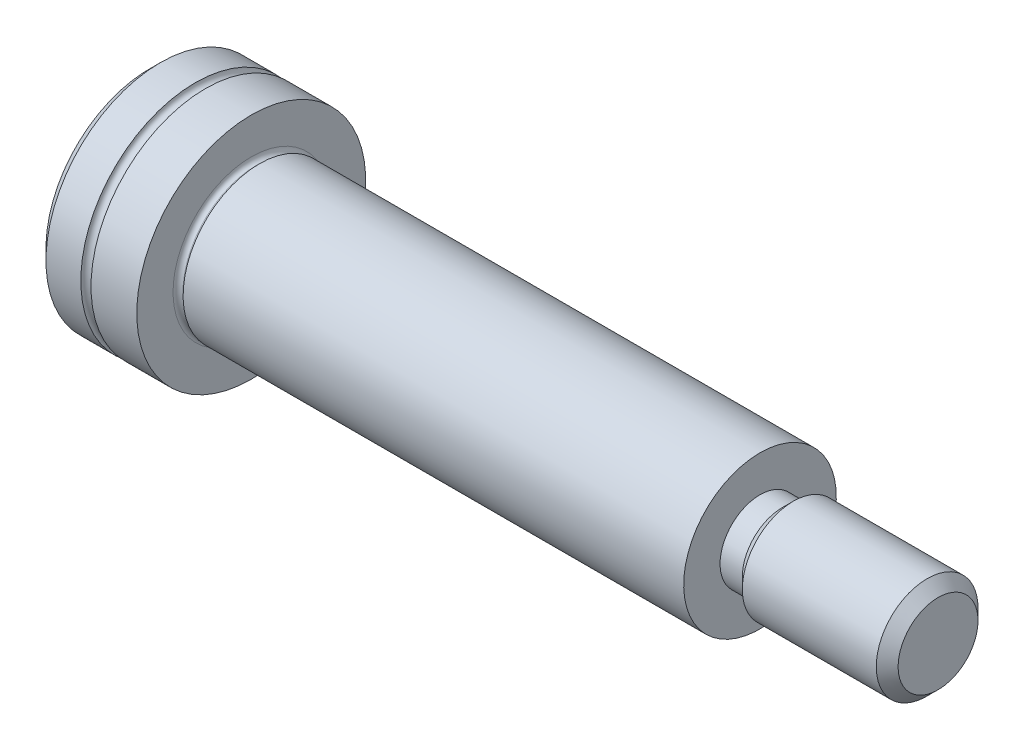
from build123d import *

# Parameters (mm, degrees)
SKETCH2_R           = 2.88
BOSS_EXTRUDE1_DEPTH = 0.250717968
SKETCH3_R           = 2.88
BOSS_EXTRUDE2_DEPTH = 0.069282032
BOSS_EXTRUDE2_TAPER = -60.000000004
SKETCH4_R           = 3
BOSS_EXTRUDE3_DEPTH = 19.68
SKETCH5_R           = 1.5705
BOSS_EXTRUDE4_DEPTH = 0.875
SKETCH6_R           = 1.5705
BOSS_EXTRUDE5_DEPTH = 0.4295
BOSS_EXTRUDE5_TAPER = -45
SKETCH7_R           = 2
BOSS_EXTRUDE6_DEPTH = 5.6955
CUT_EXTRUDE1_DEPTH  = 2
CHAMFER1_SIZE       = 0.4295
FILLET1_R           = 0.195


with BuildPart() as part:
    # Sketch1 → Revolve1 (revolve)
    with BuildSketch(Plane(origin=(0, 0, 0), x_dir=(-1, 0, 0), z_dir=(0, 0, -1))):
        with BuildLine():
            Line((0, 4.5), (0, 0))
            Line((0, 0), (4, 0))
            Line((4, 0), (4, 4.5))
            Line((4, 4.5), (2.2, 4.5))
            ThreePointArc((2.2, 4.5), (2, 4.3), (1.8, 4.5))
            Line((1.8, 4.5), (0, 4.5))
        make_face()
    revolve(axis=Axis((0, 0, 0), (-1, 0, 0)))

    # Sketch2 → Boss-Extrude1 (add)
    with BuildSketch(Plane(origin=(0, 0, 0), x_dir=(0, 0, -1), z_dir=(1, 0, 0))):
        Circle(SKETCH2_R)
    extrude(amount=BOSS_EXTRUDE1_DEPTH)

    # Sketch3 → Boss-Extrude2 (add)
    with BuildSketch(Plane(origin=(0.250717968, 0, 0), x_dir=(0, 0, -1), z_dir=(1, 0, 0))):
        Circle(SKETCH3_R)
    extrude(amount=BOSS_EXTRUDE2_DEPTH, taper=BOSS_EXTRUDE2_TAPER)

    # Sketch4 → Boss-Extrude3 (add)
    with BuildSketch(Plane(origin=(0.32, 0, 0), x_dir=(0, 0, -1), z_dir=(1, 0, 0))):
        Circle(SKETCH4_R)
    extrude(amount=BOSS_EXTRUDE3_DEPTH)

    # Sketch5 → Boss-Extrude4 (add)
    with BuildSketch(Plane(origin=(20, 0, 0), x_dir=(0, 0, -1), z_dir=(1, 0, 0))):
        Circle(SKETCH5_R)
    extrude(amount=BOSS_EXTRUDE4_DEPTH)

    # Sketch6 → Boss-Extrude5 (add)
    with BuildSketch(Plane(origin=(20.875, 0, 0), x_dir=(0, 0, -1), z_dir=(1, 0, 0))):
        Circle(SKETCH6_R)
    extrude(amount=BOSS_EXTRUDE5_DEPTH, taper=BOSS_EXTRUDE5_TAPER)

    # Sketch7 → Boss-Extrude6 (add)
    with BuildSketch(Plane(origin=(21.3045, 0, 0), x_dir=(0, 0, -1), z_dir=(1, 0, 0))):
        Circle(SKETCH7_R)
    extrude(amount=BOSS_EXTRUDE6_DEPTH)

    # Sketch8 → Cut-Extrude1 (cut)
    with BuildSketch(Plane.ZY.offset(4)):
        Polygon((1.5, -0.866025404), (1.5, 0.866025404), (0, 1.732050808), (-1.5, 0.866025404), (-1.5, -0.866025404), (0, -1.732050808), align=None)
    extrude(amount=-CUT_EXTRUDE1_DEPTH, mode=Mode.SUBTRACT)

    # Sketch9 → Cut-Revolve1 (revolve, cut)
    with BuildSketch(Plane.XY):
        Polygon((-2, 1.44), (-2, 0), (-1.168615612, 0), align=None)
    revolve(axis=Axis((-2, 0, 0), (1, 0, 0)), mode=Mode.SUBTRACT)

    # Chamfer1
    chamfer1_edges = [part.edges().sort_by_distance(p)[0] for p in [
        (27, 0, 2),
        (-4, -4.5, 0),
    ]]
    chamfer(chamfer1_edges, length=CHAMFER1_SIZE)

    # Fillet1
    fillet1_edges = [part.edges().sort_by_distance(p)[0] for p in [
        (0, 0, 2.88),
    ]]
    fillet(fillet1_edges, radius=FILLET1_R)


solid = part.part
